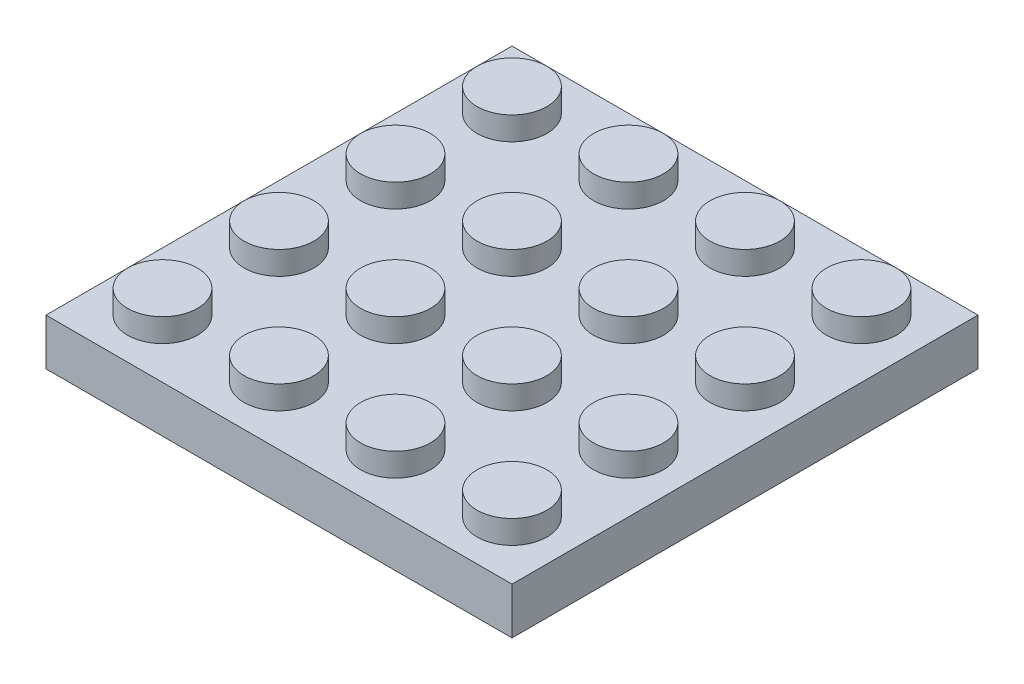
from build123d import *

# Parameters (mm, degrees)
SKETCH1_R              = 2.035533906
SKETCH1_R_2            = 1.5
BOSS_EXTRUDE1_DEPTH    = 1
SKETCH1_W              = 20
SKETCH1_H              = 20
SKETCH1_W_2            = 18
SKETCH1_H_2            = 18
BOSS_EXTRUDE1_2_DEPTH  = 1
BOSS_EXTRUDE1_3_DEPTH  = 1
BOSS_EXTRUDE1_4_DEPTH  = 1
BOSS_EXTRUDE1_5_DEPTH  = 1
BOSS_EXTRUDE1_6_DEPTH  = 1
BOSS_EXTRUDE1_7_DEPTH  = 1
BOSS_EXTRUDE1_8_DEPTH  = 1
BOSS_EXTRUDE1_9_DEPTH  = 1
BOSS_EXTRUDE1_10_DEPTH = 1
SKETCH1_3_R            = 1.5
BOSS_EXTRUDE2_DEPTH    = 2
BOSS_EXTRUDE2_2_DEPTH  = 2
BOSS_EXTRUDE2_3_DEPTH  = 2
BOSS_EXTRUDE2_4_DEPTH  = 2
BOSS_EXTRUDE2_5_DEPTH  = 2
BOSS_EXTRUDE2_6_DEPTH  = 2
BOSS_EXTRUDE2_7_DEPTH  = 2
BOSS_EXTRUDE2_8_DEPTH  = 2
BOSS_EXTRUDE2_9_DEPTH  = 2
BOSS_EXTRUDE2_10_DEPTH = 2
BOSS_EXTRUDE2_11_DEPTH = 2
BOSS_EXTRUDE2_12_DEPTH = 2
BOSS_EXTRUDE2_13_DEPTH = 2
BOSS_EXTRUDE2_14_DEPTH = 2
BOSS_EXTRUDE2_15_DEPTH = 2
BOSS_EXTRUDE2_16_DEPTH = 2
SKETCH1_4_W            = 20
SKETCH1_4_H            = 20
BOSS_EXTRUDE3_DEPTH    = 1


with BuildPart() as part:
    # Sketch1 → Boss-Extrude1 (new body)
    with BuildSketch(Plane(origin=(0, 0, 0), x_dir=(1, 0, 0), z_dir=(0, 1, 0))):
        with Locations((5, 15)):
            Circle(SKETCH1_R)
        with Locations((5, 15)):
            Circle(SKETCH1_R_2, mode=Mode.SUBTRACT)
    extrude(amount=-BOSS_EXTRUDE1_DEPTH)



with BuildPart() as body_2:
    # Sketch1 → Boss-Extrude1 2 (new body)
    with BuildSketch(Plane(origin=(0, 0, 0), x_dir=(1, 0, 0), z_dir=(0, 1, 0))):
        with Locations((10, 10)):
            Rectangle(SKETCH1_W, SKETCH1_H)
        with Locations((10, 10)):
            Rectangle(SKETCH1_W_2, SKETCH1_H_2, mode=Mode.SUBTRACT)
    extrude(amount=-BOSS_EXTRUDE1_2_DEPTH)


with BuildPart() as body_3:
    # Sketch1 → Boss-Extrude1 3 (new body)
    with BuildSketch(Plane(origin=(0, 0, 0), x_dir=(1, 0, 0), z_dir=(0, 1, 0))):
        with Locations((5, 10)):
            Circle(SKETCH1_R)
        with Locations((5, 10)):
            Circle(SKETCH1_R_2, mode=Mode.SUBTRACT)
    extrude(amount=-BOSS_EXTRUDE1_3_DEPTH)


with BuildPart() as body_4:
    # Sketch1 → Boss-Extrude1 4 (new body)
    with BuildSketch(Plane(origin=(0, 0, 0), x_dir=(1, 0, 0), z_dir=(0, 1, 0))):
        with Locations((10, 15)):
            Circle(SKETCH1_R)
        with Locations((10, 15)):
            Circle(SKETCH1_R_2, mode=Mode.SUBTRACT)
    extrude(amount=-BOSS_EXTRUDE1_4_DEPTH)


with BuildPart() as body_5:
    # Sketch1 → Boss-Extrude1 5 (new body)
    with BuildSketch(Plane(origin=(0, 0, 0), x_dir=(1, 0, 0), z_dir=(0, 1, 0))):
        with Locations((5, 5)):
            Circle(SKETCH1_R)
        with Locations((5, 5)):
            Circle(SKETCH1_R_2, mode=Mode.SUBTRACT)
    extrude(amount=-BOSS_EXTRUDE1_5_DEPTH)


with BuildPart() as body_6:
    # Sketch1 → Boss-Extrude1 6 (new body)
    with BuildSketch(Plane(origin=(0, 0, 0), x_dir=(1, 0, 0), z_dir=(0, 1, 0))):
        with Locations((10, 10)):
            Circle(SKETCH1_R)
        with Locations((10, 10)):
            Circle(SKETCH1_R_2, mode=Mode.SUBTRACT)
    extrude(amount=-BOSS_EXTRUDE1_6_DEPTH)


with BuildPart() as body_7:
    # Sketch1 → Boss-Extrude1 7 (new body)
    with BuildSketch(Plane(origin=(0, 0, 0), x_dir=(1, 0, 0), z_dir=(0, 1, 0))):
        with Locations((15, 15)):
            Circle(SKETCH1_R)
        with Locations((15, 15)):
            Circle(SKETCH1_R_2, mode=Mode.SUBTRACT)
    extrude(amount=-BOSS_EXTRUDE1_7_DEPTH)


with BuildPart() as body_8:
    # Sketch1 → Boss-Extrude1 8 (new body)
    with BuildSketch(Plane(origin=(0, 0, 0), x_dir=(1, 0, 0), z_dir=(0, 1, 0))):
        with Locations((10, 5)):
            Circle(SKETCH1_R)
        with Locations((10, 5)):
            Circle(SKETCH1_R_2, mode=Mode.SUBTRACT)
    extrude(amount=-BOSS_EXTRUDE1_8_DEPTH)


with BuildPart() as body_9:
    # Sketch1 → Boss-Extrude1 9 (new body)
    with BuildSketch(Plane(origin=(0, 0, 0), x_dir=(1, 0, 0), z_dir=(0, 1, 0))):
        with Locations((15, 10)):
            Circle(SKETCH1_R)
        with Locations((15, 10)):
            Circle(SKETCH1_R_2, mode=Mode.SUBTRACT)
    extrude(amount=-BOSS_EXTRUDE1_9_DEPTH)


with BuildPart() as body_10:
    # Sketch1 → Boss-Extrude1 10 (new body)
    with BuildSketch(Plane(origin=(0, 0, 0), x_dir=(1, 0, 0), z_dir=(0, 1, 0))):
        with Locations((15, 5)):
            Circle(SKETCH1_R)
        with Locations((15, 5)):
            Circle(SKETCH1_R_2, mode=Mode.SUBTRACT)
    extrude(amount=-BOSS_EXTRUDE1_10_DEPTH)


with BuildPart() as body_11:
    # Sketch1_3 → Boss-Extrude2 (new body)
    with BuildSketch(Plane(origin=(0, 0, 0), x_dir=(1, 0, 0), z_dir=(0, 1, 0))):
        with Locations((2.5, 12.5)):
            Circle(SKETCH1_3_R)
    extrude(amount=BOSS_EXTRUDE2_DEPTH)


with BuildPart() as body_12:
    # Sketch1_3 → Boss-Extrude2 2 (new body)
    with BuildSketch(Plane(origin=(0, 0, 0), x_dir=(1, 0, 0), z_dir=(0, 1, 0))):
        with Locations((2.5, 17.5)):
            Circle(SKETCH1_3_R)
    extrude(amount=BOSS_EXTRUDE2_2_DEPTH)


with BuildPart() as body_13:
    # Sketch1_3 → Boss-Extrude2 3 (new body)
    with BuildSketch(Plane(origin=(0, 0, 0), x_dir=(1, 0, 0), z_dir=(0, 1, 0))):
        with Locations((7.5, 12.5)):
            Circle(SKETCH1_3_R)
    extrude(amount=BOSS_EXTRUDE2_3_DEPTH)


with BuildPart() as body_14:
    # Sketch1_3 → Boss-Extrude2 4 (new body)
    with BuildSketch(Plane(origin=(0, 0, 0), x_dir=(1, 0, 0), z_dir=(0, 1, 0))):
        with Locations((2.5, 7.5)):
            Circle(SKETCH1_3_R)
    extrude(amount=BOSS_EXTRUDE2_4_DEPTH)


with BuildPart() as body_15:
    # Sketch1_3 → Boss-Extrude2 5 (new body)
    with BuildSketch(Plane(origin=(0, 0, 0), x_dir=(1, 0, 0), z_dir=(0, 1, 0))):
        with Locations((7.5, 17.5)):
            Circle(SKETCH1_3_R)
    extrude(amount=BOSS_EXTRUDE2_5_DEPTH)


with BuildPart() as body_16:
    # Sketch1_3 → Boss-Extrude2 6 (new body)
    with BuildSketch(Plane(origin=(0, 0, 0), x_dir=(1, 0, 0), z_dir=(0, 1, 0))):
        with Locations((2.5, 2.5)):
            Circle(SKETCH1_3_R)
    extrude(amount=BOSS_EXTRUDE2_6_DEPTH)


with BuildPart() as body_17:
    # Sketch1_3 → Boss-Extrude2 7 (new body)
    with BuildSketch(Plane(origin=(0, 0, 0), x_dir=(1, 0, 0), z_dir=(0, 1, 0))):
        with Locations((12.5, 12.5)):
            Circle(SKETCH1_3_R)
    extrude(amount=BOSS_EXTRUDE2_7_DEPTH)


with BuildPart() as body_18:
    # Sketch1_3 → Boss-Extrude2 8 (new body)
    with BuildSketch(Plane(origin=(0, 0, 0), x_dir=(1, 0, 0), z_dir=(0, 1, 0))):
        with Locations((7.5, 7.5)):
            Circle(SKETCH1_3_R)
    extrude(amount=BOSS_EXTRUDE2_8_DEPTH)


with BuildPart() as body_19:
    # Sketch1_3 → Boss-Extrude2 9 (new body)
    with BuildSketch(Plane(origin=(0, 0, 0), x_dir=(1, 0, 0), z_dir=(0, 1, 0))):
        with Locations((12.5, 17.5)):
            Circle(SKETCH1_3_R)
    extrude(amount=BOSS_EXTRUDE2_9_DEPTH)


with BuildPart() as body_20:
    # Sketch1_3 → Boss-Extrude2 10 (new body)
    with BuildSketch(Plane(origin=(0, 0, 0), x_dir=(1, 0, 0), z_dir=(0, 1, 0))):
        with Locations((7.5, 2.5)):
            Circle(SKETCH1_3_R)
    extrude(amount=BOSS_EXTRUDE2_10_DEPTH)


with BuildPart() as body_21:
    # Sketch1_3 → Boss-Extrude2 11 (new body)
    with BuildSketch(Plane(origin=(0, 0, 0), x_dir=(1, 0, 0), z_dir=(0, 1, 0))):
        with Locations((17.5, 17.5)):
            Circle(SKETCH1_3_R)
    extrude(amount=BOSS_EXTRUDE2_11_DEPTH)


with BuildPart() as body_22:
    # Sketch1_3 → Boss-Extrude2 12 (new body)
    with BuildSketch(Plane(origin=(0, 0, 0), x_dir=(1, 0, 0), z_dir=(0, 1, 0))):
        with Locations((17.5, 12.5)):
            Circle(SKETCH1_3_R)
    extrude(amount=BOSS_EXTRUDE2_12_DEPTH)


with BuildPart() as body_23:
    # Sketch1_3 → Boss-Extrude2 13 (new body)
    with BuildSketch(Plane(origin=(0, 0, 0), x_dir=(1, 0, 0), z_dir=(0, 1, 0))):
        with Locations((12.5, 7.5)):
            Circle(SKETCH1_3_R)
    extrude(amount=BOSS_EXTRUDE2_13_DEPTH)


with BuildPart() as body_24:
    # Sketch1_3 → Boss-Extrude2 14 (new body)
    with BuildSketch(Plane(origin=(0, 0, 0), x_dir=(1, 0, 0), z_dir=(0, 1, 0))):
        with Locations((12.5, 2.5)):
            Circle(SKETCH1_3_R)
    extrude(amount=BOSS_EXTRUDE2_14_DEPTH)


with BuildPart() as body_25:
    # Sketch1_3 → Boss-Extrude2 15 (new body)
    with BuildSketch(Plane(origin=(0, 0, 0), x_dir=(1, 0, 0), z_dir=(0, 1, 0))):
        with Locations((17.5, 2.5)):
            Circle(SKETCH1_3_R)
    extrude(amount=BOSS_EXTRUDE2_15_DEPTH)


with BuildPart() as body_26:
    # Sketch1_3 → Boss-Extrude2 16 (new body)
    with BuildSketch(Plane(origin=(0, 0, 0), x_dir=(1, 0, 0), z_dir=(0, 1, 0))):
        with Locations((17.5, 7.5)):
            Circle(SKETCH1_3_R)
    extrude(amount=BOSS_EXTRUDE2_16_DEPTH)


with BuildPart() as part_1:
    add(part.part)

    add(body_2.part)  # Boss-Extrude3 merges body 2

    add(body_3.part)  # Boss-Extrude3 merges body 3

    add(body_4.part)  # Boss-Extrude3 merges body 4

    add(body_5.part)  # Boss-Extrude3 merges body 5

    add(body_6.part)  # Boss-Extrude3 merges body 6

    add(body_7.part)  # Boss-Extrude3 merges body 7

    add(body_8.part)  # Boss-Extrude3 merges body 8

    add(body_9.part)  # Boss-Extrude3 merges body 9

    add(body_10.part)  # Boss-Extrude3 merges body 10

    add(body_11.part)  # Boss-Extrude3 merges body 11

    add(body_12.part)  # Boss-Extrude3 merges body 12

    add(body_13.part)  # Boss-Extrude3 merges body 13

    add(body_14.part)  # Boss-Extrude3 merges body 14

    add(body_15.part)  # Boss-Extrude3 merges body 15

    add(body_16.part)  # Boss-Extrude3 merges body 16

    add(body_17.part)  # Boss-Extrude3 merges body 17

    add(body_18.part)  # Boss-Extrude3 merges body 18

    add(body_19.part)  # Boss-Extrude3 merges body 19

    add(body_20.part)  # Boss-Extrude3 merges body 20

    add(body_21.part)  # Boss-Extrude3 merges body 21

    add(body_22.part)  # Boss-Extrude3 merges body 22

    add(body_23.part)  # Boss-Extrude3 merges body 23

    add(body_24.part)  # Boss-Extrude3 merges body 24

    add(body_25.part)  # Boss-Extrude3 merges body 25

    add(body_26.part)  # Boss-Extrude3 merges body 26
    # Sketch1_4 → Boss-Extrude3 (add)
    with BuildSketch(Plane(origin=(0, 0, 0), x_dir=(1, 0, 0), z_dir=(0, 1, 0))):
        with Locations((10, 10)):
            Rectangle(SKETCH1_4_W, SKETCH1_4_H)
    extrude(amount=BOSS_EXTRUDE3_DEPTH)


solid = part_1.part
